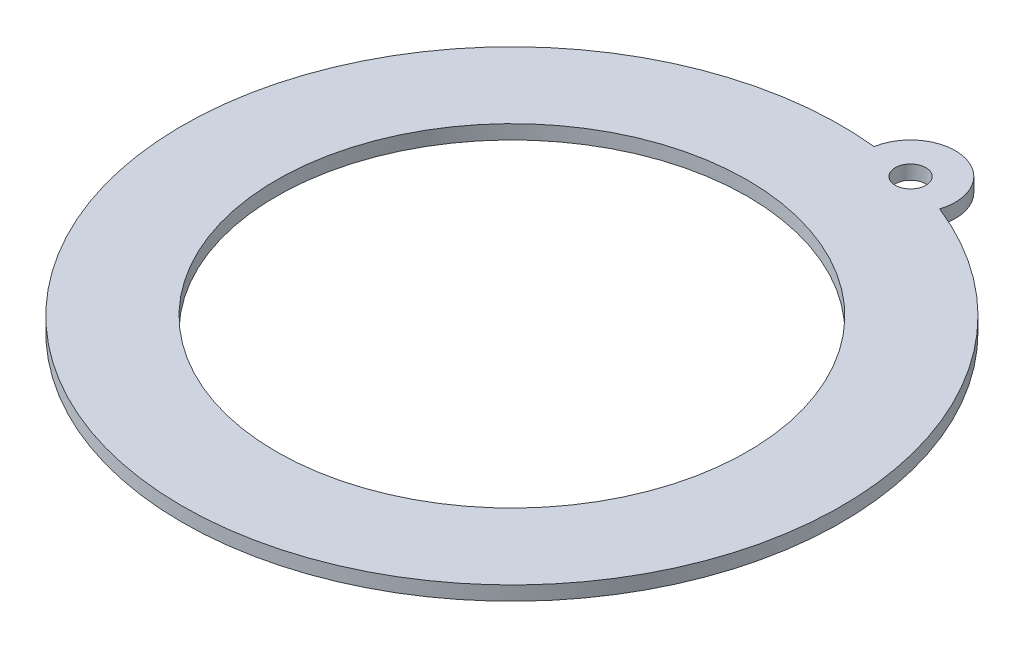
from build123d import *

# Parameters (mm, degrees)
SKETCH1_R           = 50
SKETCH1_R_2         = 3.25
BOSS_EXTRUDE1_DEPTH = 3


with BuildPart() as part:
    # Sketch1 → Boss-Extrude1 (new body)
    with BuildSketch(Plane(origin=(0, 0, 0), x_dir=(1, 0, 0), z_dir=(0, 1, 0))):
        with BuildLine():
            ThreePointArc((7.33552118, 69.614582732), (-16.693883906, -67.980248897), (25.744772546, 65.093829865))
            ThreePointArc((25.744772546, 65.093829865), (18.959482437, 77.206139819), (7.33552118, 69.614582732))
        make_face()
        Circle(SKETCH1_R, mode=Mode.SUBTRACT)
        with Locations((16.693883906, 67.980248897)):
            Circle(SKETCH1_R_2, mode=Mode.SUBTRACT)
    extrude(amount=BOSS_EXTRUDE1_DEPTH)


solid = part.part
